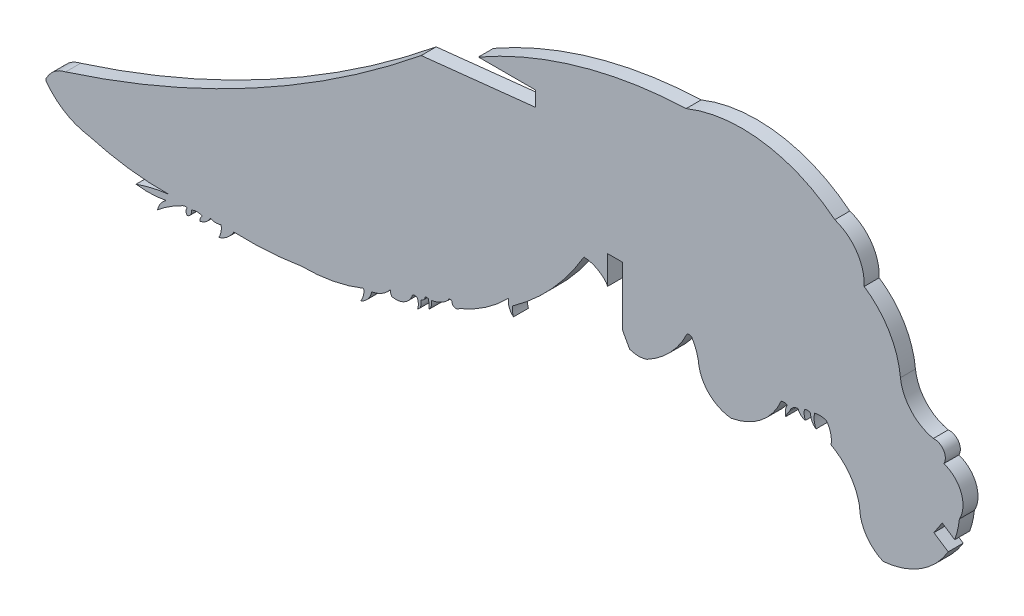
from build123d import *

# Parameters (mm, degrees)
BOSS_EXTRUDE1_DEPTH = 1.524
SKETCH2_W           = 1.524
SKETCH2_H           = 5.96660367
CUT_EXTRUDE3_DEPTH  = 135.253240476


with BuildPart() as part:
    # Sketch1 → Boss-Extrude1 (new body)
    with BuildSketch(Plane.XY):
        with BuildLine():
            Line((52.749938031, 70.131845749), (64.371465794, 71.381472391))
            Line((64.371465794, 71.381472391), (64.371465794, 72.905472391))
            Line((64.371465794, 72.905472391), (58.560701913, 72.905472391))
            ThreePointArc((58.560701913, 72.905472391), (68.751288874, 77.18302052), (79.665108288, 78.924866217))
            ThreePointArc((79.665108288, 78.924866217), (87.51605356, 79.864840631), (94.759202069, 76.693453987))
            ThreePointArc((94.759202069, 76.693453987), (96.985502082, 75.005001445), (97.746636466, 72.316515219))
            ThreePointArc((97.746636466, 72.316515219), (100.280996817, 69.637712422), (101.428823049, 66.133220769))
            ThreePointArc((101.428823049, 66.133220769), (102.504441665, 63.756169776), (104.763633539, 62.451034186))
            ThreePointArc((104.763633539, 62.451034186), (105.815523966, 61.94348794), (105.834353574, 60.775702811))
            ThreePointArc((105.834353574, 60.775702811), (107.593647808, 59.110829557), (107.413611762, 56.69535731))
            ThreePointArc((107.413611762, 56.69535731), (104.915486102, 51.493806045), (99.669748601, 49.089849838))
            ThreePointArc((99.669748601, 49.089849838), (97.93078373, 50.558543058), (97.277362732, 52.738932839))
            ThreePointArc((97.277362732, 52.738932839), (96.275148178, 55.045205965), (94.377694548, 56.69535731))
            ThreePointArc((94.377694548, 56.69535731), (94.341947265, 57.697226126), (93.911436782, 58.602587774))
            ThreePointArc((93.911436782, 58.602587774), (93.31755476, 58.718236433), (92.715544448, 58.657787675))
            ThreePointArc((92.715544448, 58.657787675), (92.668251349, 57.985085863), (92.857476868, 57.337816162))
            ThreePointArc((92.857476868, 57.337816162), (92.437007408, 57.816991843), (92.308352921, 58.441373075))
            ThreePointArc((92.308352921, 58.441373075), (91.998939648, 58.544100362), (91.680077423, 58.476156637))
            ThreePointArc((91.680077423, 58.476156637), (91.653768646, 58.005927685), (91.779444676, 57.552041185))
            ThreePointArc((91.779444676, 57.552041185), (91.306585055, 57.779976677), (91.03290283, 58.22791512))
            ThreePointArc((91.03290283, 58.22791512), (90.50619799, 58.023829811), (90.170237064, 57.569738347))
            ThreePointArc((90.170237064, 57.569738347), (89.940738286, 57.243637966), (89.778811712, 56.879233065))
            ThreePointArc((89.778811712, 56.879233065), (89.744476135, 57.449042317), (89.940738286, 57.985085863))
            ThreePointArc((89.940738286, 57.985085863), (89.626896453, 58.063679483), (89.308840631, 58.00439924))
            ThreePointArc((89.308840631, 58.00439924), (87.283822401, 55.344960061), (84.23724791, 53.969569406))
            ThreePointArc((84.23724791, 53.969569406), (82.119422653, 54.881253432), (80.968584276, 56.879233065))
            ThreePointArc((80.968584276, 56.879233065), (80.728221934, 58.038765282), (80.225263479, 59.110829557))
            ThreePointArc((80.225263479, 59.110829557), (79.990436789, 59.199276584), (79.74821764, 59.133730156))
            ThreePointArc((79.74821764, 59.133730156), (78.063200875, 56.684963047), (75.700496179, 54.881253432))
            ThreePointArc((75.700496179, 54.881253432), (74.814943925, 54.724384759), (73.92939167, 54.881253432))
            ThreePointArc((73.92939167, 54.881253432), (72.689360724, 57.184690211), (71.555199225, 59.542056419))
            ThreePointArc((71.555199225, 59.542056419), (70.53318823, 60.33987445), (69.280379472, 60.673776077))
            ThreePointArc((69.280379472, 60.673776077), (66.074534091, 56.320096732), (62.023949735, 52.738932839))
            ThreePointArc((62.023949735, 52.738932839), (62.018158819, 52.275784748), (62.122280661, 51.824455233))
            ThreePointArc((62.122280661, 51.824455233), (61.681410811, 52.454602529), (61.618245883, 53.221063245))
            ThreePointArc((61.618245883, 53.221063245), (59.29856558, 51.252524719), (56.623131886, 49.804037512))
            ThreePointArc((56.623131886, 49.804037512), (56.143365032, 49.668212915), (55.855452098, 50.075313269))
            ThreePointArc((55.855452098, 50.075313269), (55.634539123, 50.152406549), (55.491712516, 49.967078524))
            ThreePointArc((55.491712516, 49.967078524), (54.711546462, 49.408479108), (53.79819099, 49.114414214))
            ThreePointArc((53.79819099, 49.114414214), (53.781075658, 48.622130566), (53.534831875, 48.19551584))
            ThreePointArc((53.534831875, 48.19551584), (53.542028616, 48.644457223), (53.48523445, 49.089849838))
            ThreePointArc((53.48523445, 49.089849838), (53.3082991, 49.130815552), (53.13136375, 49.089849838))
            ThreePointArc((53.13136375, 49.089849838), (53.00604404, 48.779905646), (52.700390386, 48.644457223))
            ThreePointArc((52.700390386, 48.644457223), (52.714349204, 48.082434529), (52.379221144, 47.631043855))
            ThreePointArc((52.379221144, 47.631043855), (52.460297524, 48.107812169), (52.379221144, 48.584580484))
            ThreePointArc((52.379221144, 48.584580484), (52.12852371, 48.695194866), (51.864428363, 48.622130566))
            ThreePointArc((51.864428363, 48.622130566), (51.051818187, 47.620090335), (49.775293704, 47.433261089))
            ThreePointArc((49.775293704, 47.433261089), (49.651036263, 47.688587532), (49.62023506, 47.970868935))
            ThreePointArc((49.62023506, 47.970868935), (48.780471907, 47.225294105), (47.727759637, 46.834294287))
            ThreePointArc((47.727759637, 46.834294287), (47.331273993, 46.008852436), (46.594544028, 45.464992092))
            ThreePointArc((46.594544028, 45.464992092), (46.877970347, 46.066432963), (46.906161005, 46.730712185))
            ThreePointArc((46.906161005, 46.730712185), (43.798654282, 45.811386919), (40.571228797, 45.519014346))
            ThreePointArc((40.571228797, 45.519014346), (37.159419224, 45.129203066), (33.725626021, 45.090971596))
            ThreePointArc((33.725626021, 45.090971596), (33.068999074, 44.320201948), (32.178585471, 43.838114389))
            ThreePointArc((32.178585471, 43.838114389), (32.418564973, 44.441560177), (32.417226894, 45.090971596))
            ThreePointArc((32.417226894, 45.090971596), (31.873442168, 44.988363543), (31.332044302, 45.102899962))
            ThreePointArc((31.332044302, 45.102899962), (30.887683341, 44.585264996), (30.259078376, 44.320201948))
            ThreePointArc((30.259078376, 44.320201948), (30.326970235, 44.626264328), (30.531184649, 44.864129748))
            ThreePointArc((30.531184649, 44.864129748), (29.980102952, 45.010427729), (29.429021254, 44.864129748))
            ThreePointArc((29.429021254, 44.864129748), (29.340661001, 44.432357132), (28.989623083, 44.165884794))
            ThreePointArc((28.989623083, 44.165884794), (28.864149038, 44.515007271), (28.989623083, 44.864129748))
            ThreePointArc((28.989623083, 44.864129748), (28.628355518, 44.84783713), (28.30893512, 44.678277961))
            ThreePointArc((28.30893512, 44.678277961), (27.079850519, 43.991023465), (25.955408412, 43.143322074))
            ThreePointArc((25.955408412, 43.143322074), (26.282852866, 43.874201462), (26.857193183, 44.432357132))
            ThreePointArc((26.857193183, 44.432357132), (25.328745526, 44.244978672), (23.791384091, 44.333198545))
            ThreePointArc((23.791384091, 44.333198545), (25.414182464, 44.809450383), (27.079850519, 45.102435547))
            ThreePointArc((27.079850519, 45.102435547), (23.023366565, 45.343696153), (19.045869652, 46.176034458))
            ThreePointArc((19.045869652, 46.176034458), (16.652090777, 47.015108036), (14.752643777, 48.696275152))
            ThreePointArc((14.752643777, 48.696275152), (14.640422349, 48.961729487), (14.752643777, 49.227183822))
            ThreePointArc((14.752643777, 49.227183822), (15.539561177, 50.138860369), (16.635728101, 50.637670147))
            ThreePointArc((16.635728101, 50.637670147), (35.605852794, 58.693330375), (52.749938031, 70.131845749))
        make_face()
    extrude(amount=BOSS_EXTRUDE1_DEPTH)

    # Sketch2 → Cut-Extrude3 (cut, through all)
    with BuildSketch(Plane.XY.offset(1.524)):
        with Locations((72.435845658, 59.192908392)):
            Rectangle(SKETCH2_W, SKETCH2_H)
        Polygon((106.940547802, 54.636029996), (106.397081003, 53.169068481), (104.827290354, 54.203248276), (105.665710767, 55.475894028), align=None)
    extrude(amount=-CUT_EXTRUDE3_DEPTH, mode=Mode.SUBTRACT)


with BuildPart() as cut_extrude3_kept_piece:
    # of the separate pieces the step leaves, the one the design keeps (cut_extrude3_pieces_kept)
    add(part.part.solids().sort_by_distance((16.635728101, 50.637670147, 0))[0])


solid = cut_extrude3_kept_piece.part
